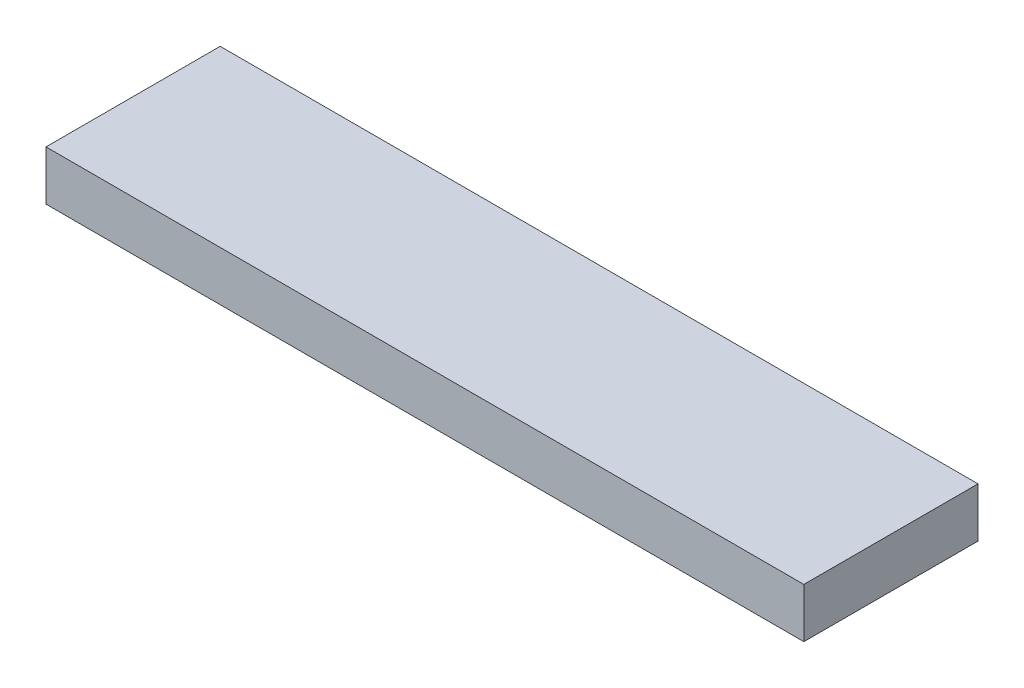
from build123d import *

# Parameters (mm, degrees)
SKETCH1_W           = 97.028
SKETCH1_H           = 22.3012
BOSS_EXTRUDE1_DEPTH = 6.35


with BuildPart() as part:
    # Sketch1 → Boss-Extrude1 (new body)
    with BuildSketch(Plane(origin=(0, -31.18166681, 0), x_dir=(1, 0, 0), z_dir=(0, 1, 0))):
        with Locations((134.536700428, -62.589765743)):
            Rectangle(SKETCH1_W, SKETCH1_H)
    extrude(amount=BOSS_EXTRUDE1_DEPTH)


solid = part.part
